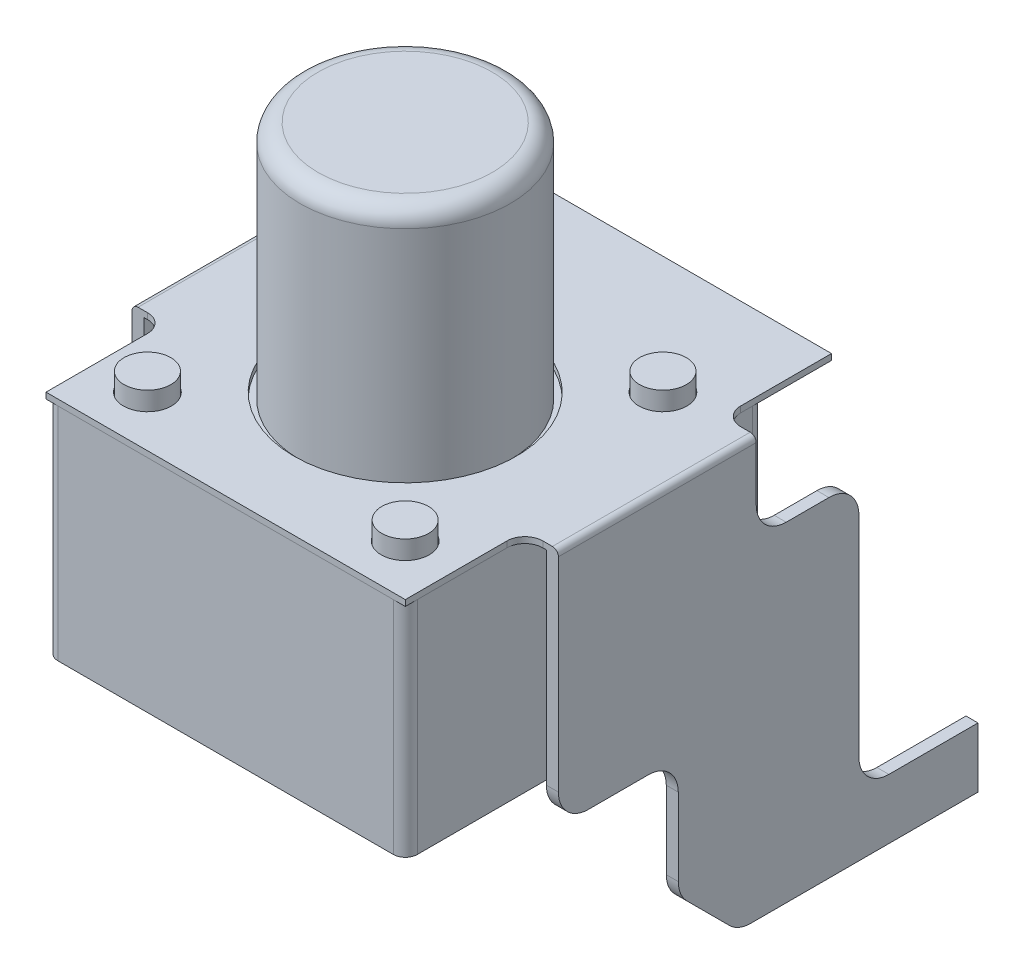
from build123d import *

# Parameters (mm, degrees)
SKETCH1_W           = 5.9944
SKETCH1_H           = 5.99
EXTRUDE1_DEPTH      = 3.683
EXTRUDE2_DEPTH      = 0.2
FILLET3_R           = 0.5
SKETCH6_R           = 1.8526
SKETCH6_R_2         = 0.4
EXTRUDE3_DEPTH      = 0.1
SKETCH2_R           = 1.7526
EXTRUDE4_DEPTH      = 4
FILLET1_R           = 0.1
SKETCH8_R           = 0.39
BOSS_EXTRUDE1_DEPTH = 0.4048
FILLET4_R           = 0.2
FILLET5_R           = 0.3


with BuildPart() as part:
    # Sketch1 → Extrude1 (new body)
    with BuildSketch(Plane(origin=(0, 0, 0), x_dir=(1, 0, 0), z_dir=(0, 1, 0))):
        Rectangle(SKETCH1_W, SKETCH1_H)
    extrude(amount=-EXTRUDE1_DEPTH)

    # Sketch8 → Boss-Extrude1 (add)
    with BuildSketch(Plane(origin=(0, 0, 0), x_dir=(1, 0, 0), z_dir=(0, 1, 0))):
        with Locations((2.15, 2.15)):
            Circle(SKETCH8_R)
        with Locations((2.15, -2.15)):
            Circle(SKETCH8_R)
        with Locations((-2.15, 2.15)):
            Circle(SKETCH8_R)
        with Locations((-2.15, -2.15)):
            Circle(SKETCH8_R)
    extrude(amount=BOSS_EXTRUDE1_DEPTH)

    # Fillet4
    fillet4_edges = [part.edges().sort_by_distance(p)[0] for p in [
        (-2.9972, -1.8415, -2.995),
        (2.9972, -1.8415, -2.995),
        (2.9972, -1.8415, 2.995),
        (-2.9972, -1.8415, 2.995),
    ]]
    fillet(fillet4_edges, radius=FILLET4_R)


with BuildPart() as body_2:
    # Sketch5 → Extrude2 (new body)
    with BuildSketch(Plane(origin=(3.556, 0, 0), x_dir=(0, 0, -1), z_dir=(1, 0, 0))):
        Polygon((2.3, 0.1), (-1, 0.1), (-1, -3.9), (1, -3.9), (1, -5.9), (2, -6.9), (6, -6.9), (6, -5.9), (4.0132, -5.9), (4.0132, -1.4), (2.3, -1.4), align=None)
    extrude(amount=-EXTRUDE2_DEPTH)

    # Fillet3
    fillet3_edges = [body_2.edges().sort_by_distance(p)[0] for p in [
        (3.456, -3.9, 1),
        (3.456, -1.4, -2.3),
        (3.456, -1.4, -4.0132),
        (3.456, -5.9, -4.0132),
        (3.456, -6.9, -2),
        (3.456, -5.9, -1),
        (3.456, -3.9, -1),
    ]]
    fillet(fillet3_edges, radius=FILLET3_R)


with BuildPart() as body_3:
    # Mirror1: mirrored copy
    add(body_2.part.mirror(Plane(origin=(0, 0, 0), x_dir=(0, 0, 1), z_dir=(1, 0, 0))))


with BuildPart() as body_2_1:
    add(body_2.part)

    add(body_3.part)  # Extrude3 merges body 3
    # Sketch6 → Extrude3 (add, through all)
    with BuildSketch(Plane(origin=(0, 0, 0), x_dir=(1, 0, 0), z_dir=(0, 1, 0))):
        with BuildLine():
            Line((3.2972, -1), (3.556, -1))
            Line((3.556, -1), (3.556, 2.3))
            Line((3.556, 2.3), (3.2972, 2.3))
            ThreePointArc((3.2972, 2.3), (3.085067966, 2.387867966), (2.9972, 2.6))
            Line((2.9972, 2.6), (2.9972, 4.115))
            Line((2.9972, 4.115), (-2.9972, 4.115))
            Line((-2.9972, 4.115), (-2.9972, 2.6))
            ThreePointArc((-2.9972, 2.6), (-3.085067966, 2.387867966), (-3.2972, 2.3))
            Line((-3.2972, 2.3), (-3.556, 2.3))
            Line((-3.556, 2.3), (-3.556, -1))
            Line((-3.556, -1), (-3.2972, -1))
            ThreePointArc((-3.2972, -1), (-3.085067966, -1.087867966), (-2.9972, -1.3))
            Line((-2.9972, -1.3), (-2.9972, -2.995))
            Line((-2.9972, -2.995), (2.9972, -2.995))
            Line((2.9972, -2.995), (2.9972, -1.3))
            ThreePointArc((2.9972, -1.3), (3.085067966, -1.087867966), (3.2972, -1))
        make_face()
        Circle(SKETCH6_R, mode=Mode.SUBTRACT)
        with Locations((-2.15, 2.15)):
            Circle(SKETCH6_R_2, mode=Mode.SUBTRACT)
        with Locations((2.15, 2.15)):
            Circle(SKETCH6_R_2, mode=Mode.SUBTRACT)
        with Locations((2.15, -2.15)):
            Circle(SKETCH6_R_2, mode=Mode.SUBTRACT)
        with Locations((-2.15, -2.15)):
            Circle(SKETCH6_R_2, mode=Mode.SUBTRACT)
    extrude(amount=EXTRUDE3_DEPTH)

    # Fillet1
    fillet1_edges = [body_2_1.edges().sort_by_distance(p)[0] for p in [
        (3.556, 0.1, -0.65),
        (-3.556, 0.1, -0.65),
    ]]
    fillet(fillet1_edges, radius=FILLET1_R)


with BuildPart() as body_3_2:
    # Sketch2 → Extrude4 (new body)
    with BuildSketch(Plane(origin=(0, 0, 0), x_dir=(1, 0, 0), z_dir=(0, 1, 0))):
        Circle(SKETCH2_R)
    extrude(amount=EXTRUDE4_DEPTH)

    # Fillet5
    fillet5_edges = [body_3_2.edges().sort_by_distance(p)[0] for p in [
        (-1.7526, 4, 0),
    ]]
    fillet(fillet5_edges, radius=FILLET5_R)


solid = Compound([part.part, body_2_1.part, body_3_2.part])
